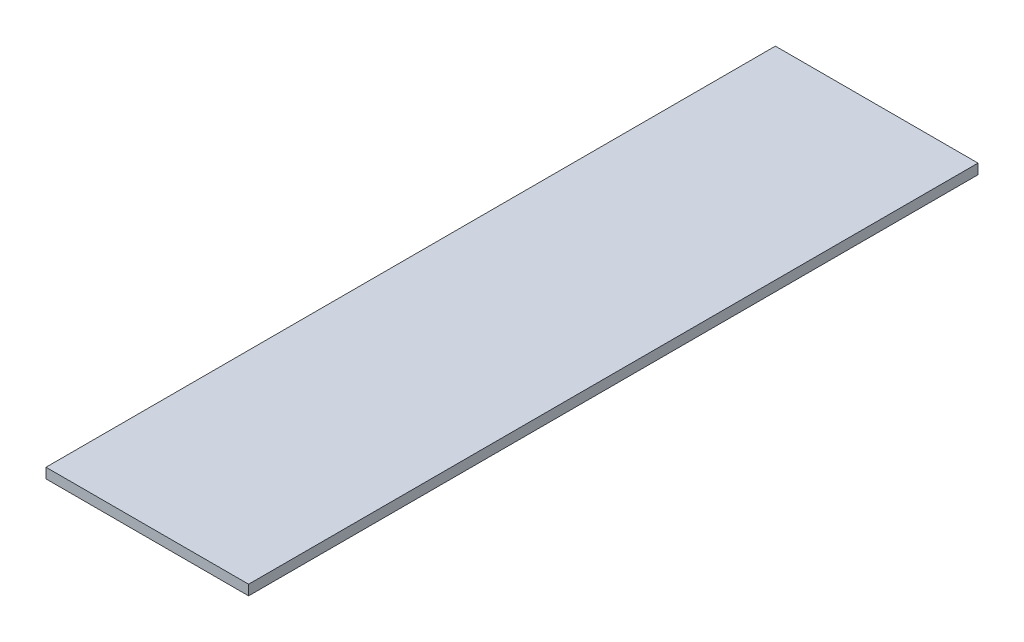
from build123d import *

# Parameters (mm, degrees)
SKETCH1_W           = 127
SKETCH1_H           = 457.2
BOSS_EXTRUDE1_DEPTH = 6.35


with BuildPart() as part:
    # Sketch1 → Boss-Extrude1 (new body)
    with BuildSketch(Plane(origin=(0, 0, 0), x_dir=(1, 0, 0), z_dir=(0, 1, 0))):
        with Locations((63.5, 228.6)):
            Rectangle(SKETCH1_W, SKETCH1_H)
    extrude(amount=BOSS_EXTRUDE1_DEPTH)


solid = part.part
